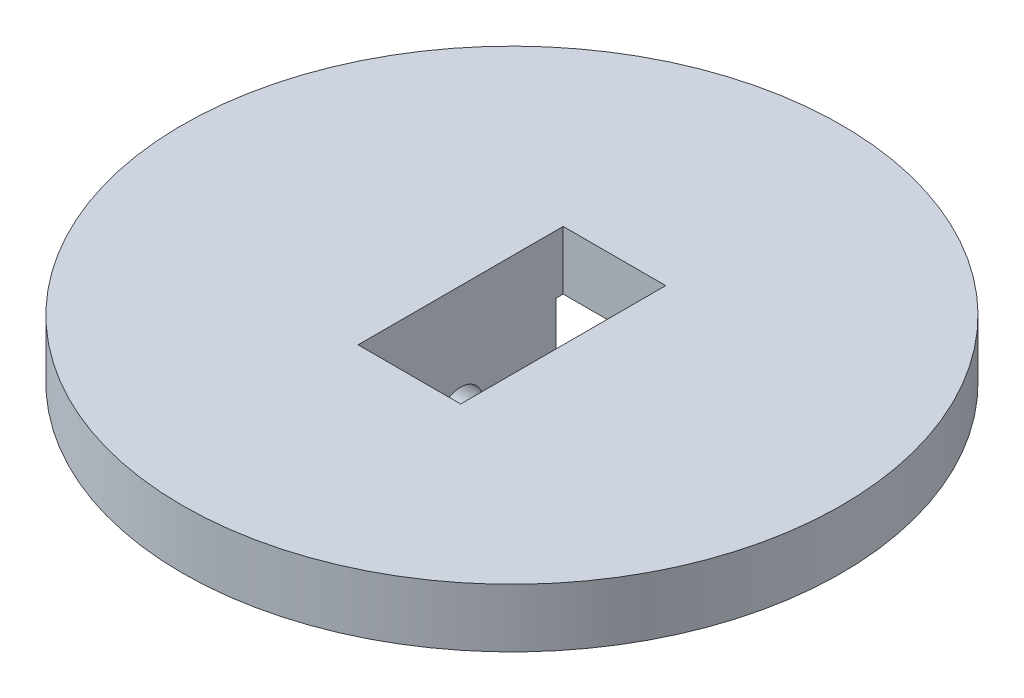
from build123d import *

# Parameters (mm, degrees)
SKETCH1_R               = 22.5
BOSS_EXTRUDE1_DEPTH     = 4
SKETCH3_W               = 14
SKETCH3_H               = 11
BOSS_EXTRUDE2_DEPTH     = 6.5
SKETCH4_W               = 7
SKETCH4_H               = 14
CUT_EXTRUDE1_DEPTH      = 5
CUT_EXTRUDE1_DEPTH_BACK = 8
SKETCH5_R               = 1.5
CUT_EXTRUDE2_DEPTH      = 23.5
CUT_EXTRUDE2_DEPTH_BACK = 23.5


with BuildPart() as part:
    # Sketch1 → Boss-Extrude1 (new body)
    with BuildSketch(Plane(origin=(0, 0, 0), x_dir=(1, 0, 0), z_dir=(0, 1, 0))):
        Circle(SKETCH1_R)
    extrude(amount=BOSS_EXTRUDE1_DEPTH)

    # Sketch3 → Boss-Extrude2 (add, symmetric)
    with BuildSketch(Plane.XY):
        with Locations((0, -1.5)):
            Rectangle(SKETCH3_W, SKETCH3_H)
    extrude(amount=BOSS_EXTRUDE2_DEPTH, both=True)

    # Sketch4 → Cut-Extrude1 (cut, two sides)
    with BuildSketch(Plane(origin=(0, 0, 0), x_dir=(1, 0, 0), z_dir=(0, 1, 0))) as cut_extrude1_sk:
        Rectangle(SKETCH4_W, SKETCH4_H)
    extrude(amount=CUT_EXTRUDE1_DEPTH, mode=Mode.SUBTRACT)
    extrude(cut_extrude1_sk.sketch, amount=-CUT_EXTRUDE1_DEPTH_BACK, mode=Mode.SUBTRACT)

    # Sketch5 → Cut-Extrude2 (cut, two sides)
    with BuildSketch(Plane(origin=(0, 0, 0), x_dir=(0, 0, -1), z_dir=(1, 0, 0))) as cut_extrude2_sk:
        with Locations((0, -3.5)):
            Circle(SKETCH5_R)
    extrude(amount=CUT_EXTRUDE2_DEPTH, mode=Mode.SUBTRACT)
    extrude(cut_extrude2_sk.sketch, amount=-CUT_EXTRUDE2_DEPTH_BACK, mode=Mode.SUBTRACT)


solid = part.part
